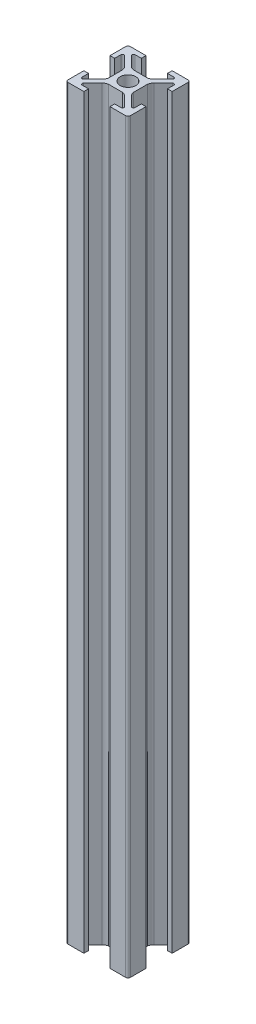
from build123d import *

# Parameters (mm, degrees)
SKETCH1_R           = 2.5
BOSS_EXTRUDE1_DEPTH = 240


with BuildPart() as part:
    # Sketch1 → Boss-Extrude1 (new body)
    with BuildSketch(Plane(origin=(0, 0, 0), x_dir=(1, 0, 0), z_dir=(0, 1, 0))):
        with BuildLine():
            Line((-3.610984523, 4.671644695), (-6.585786438, 7.646446609))
            ThreePointArc((-6.585786438, 7.646446609), (-6.694172813, 8.191341716), (-6.232233047, 8.5))
            Line((-6.232233047, 8.5), (-4.2, 8.5))
            Line((-4.2, 8.5), (-4.2, 10))
            Line((-4.2, 10), (-9.25, 10))
            ThreePointArc((-9.25, 10), (-9.780330086, 9.780330086), (-10, 9.25))
            Line((-10, 9.25), (-10, 4.2))
            Line((-10, 4.2), (-8.5, 4.2))
            Line((-8.5, 4.2), (-8.5, 6.232233047))
            ThreePointArc((-8.5, 6.232233047), (-8.191341716, 6.694172813), (-7.646446609, 6.585786438))
            Line((-7.646446609, 6.585786438), (-4.671644695, 3.610984523))
            ThreePointArc((-4.671644695, 3.610984523), (-4.244383234, 2.985253206), (-4, 2.268058063))
            Line((-4, 2.268058063), (-4, -2.268058063))
            ThreePointArc((-4, -2.268058063), (-4.244383234, -2.985253206), (-4.671644695, -3.610984523))
            Line((-4.671644695, -3.610984523), (-7.646446609, -6.585786438))
            ThreePointArc((-7.646446609, -6.585786438), (-8.191341716, -6.694172813), (-8.5, -6.232233047))
            Line((-8.5, -6.232233047), (-8.5, -4.2))
            Line((-8.5, -4.2), (-10, -4.2))
            Line((-10, -4.2), (-10, -9.25))
            ThreePointArc((-10, -9.25), (-9.780330086, -9.780330086), (-9.25, -10))
            Line((-9.25, -10), (-4.2, -10))
            Line((-4.2, -10), (-4.2, -8.5))
            Line((-4.2, -8.5), (-6.232233047, -8.5))
            ThreePointArc((-6.232233047, -8.5), (-6.694172813, -8.191341716), (-6.585786438, -7.646446609))
            Line((-6.585786438, -7.646446609), (-3.610984523, -4.671644695))
            ThreePointArc((-3.610984523, -4.671644695), (-2.985253206, -4.244383234), (-2.268058063, -4))
            Line((-2.268058063, -4), (2.268058063, -4))
            ThreePointArc((2.268058063, -4), (2.985253206, -4.244383234), (3.610984523, -4.671644695))
            Line((3.610984523, -4.671644695), (6.585786438, -7.646446609))
            ThreePointArc((6.585786438, -7.646446609), (6.694172813, -8.191341716), (6.232233047, -8.5))
            Line((6.232233047, -8.5), (4.2, -8.5))
            Line((4.2, -8.5), (4.2, -10))
            Line((4.2, -10), (9.25, -10))
            ThreePointArc((9.25, -10), (9.780330086, -9.780330086), (10, -9.25))
            Line((10, -9.25), (10, -4.2))
            Line((10, -4.2), (8.5, -4.2))
            Line((8.5, -4.2), (8.5, -6.232233047))
            ThreePointArc((8.5, -6.232233047), (8.191341716, -6.694172813), (7.646446609, -6.585786438))
            Line((7.646446609, -6.585786438), (4.671644695, -3.610984523))
            ThreePointArc((4.671644695, -3.610984523), (4.244383234, -2.985253206), (4, -2.268058063))
            Line((4, -2.268058063), (4, 2.268058063))
            ThreePointArc((4, 2.268058063), (4.244383234, 2.985253206), (4.671644695, 3.610984523))
            Line((4.671644695, 3.610984523), (7.646446609, 6.585786438))
            ThreePointArc((7.646446609, 6.585786438), (8.191341716, 6.694172813), (8.5, 6.232233047))
            Line((8.5, 6.232233047), (8.5, 4.2))
            Line((8.5, 4.2), (10, 4.2))
            Line((10, 4.2), (10, 9.25))
            ThreePointArc((10, 9.25), (9.780330086, 9.780330086), (9.25, 10))
            Line((9.25, 10), (4.2, 10))
            Line((4.2, 10), (4.2, 8.5))
            Line((4.2, 8.5), (6.232233047, 8.5))
            ThreePointArc((6.232233047, 8.5), (6.694172813, 8.191341716), (6.585786438, 7.646446609))
            Line((6.585786438, 7.646446609), (3.610984523, 4.671644695))
            ThreePointArc((3.610984523, 4.671644695), (2.985253206, 4.244383234), (2.268058063, 4))
            Line((2.268058063, 4), (-2.268058063, 4))
            ThreePointArc((-2.268058063, 4), (-2.985253206, 4.244383234), (-3.610984523, 4.671644695))
        make_face()
        Circle(SKETCH1_R, mode=Mode.SUBTRACT)
    extrude(amount=BOSS_EXTRUDE1_DEPTH)


solid = part.part
